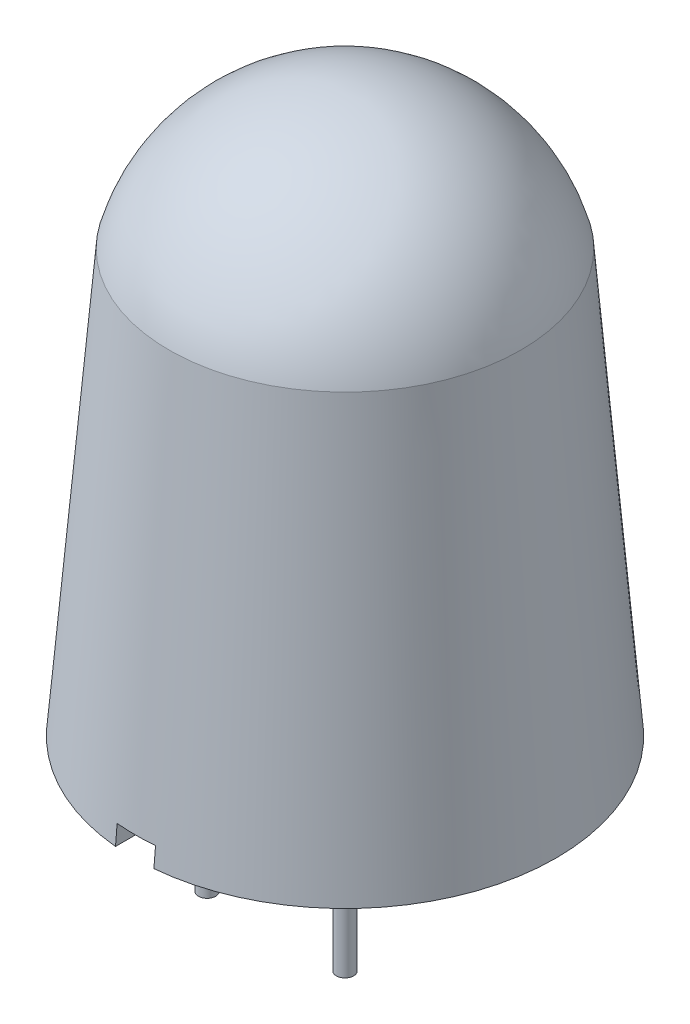
from build123d import *

# Parameters (mm, degrees)
SKETCH2_R               = 5
CUT_EXTRUDE1_DEPTH      = 1
CUT_EXTRUDE2_DEPTH      = 12
CUT_EXTRUDE2_DEPTH_BACK = 17.454482672
SKETCH3_W               = 1
SKETCH3_H               = 1
SKETCH4_R               = 0.225
BOSS_EXTRUDE1_DEPTH     = 4.5


with BuildPart() as part:
    # Sketch1 → Revolve1 (revolve)
    with BuildSketch(Plane.XY):
        with BuildLine():
            Line((0, 0), (5.5, 0))
            Line((5.5, 0), (4.582575695, 11))
            ThreePointArc((4.582575695, 11), (2.883140649, 13.524917218), (0, 14.5))
            Line((0, 14.5), (0, 0))
        make_face()
    revolve(axis=Axis((0, 0, 0), (0, 1, 0)))

    # Sketch2 → Cut-Extrude1 (cut)
    with BuildSketch(Plane.XZ):
        Circle(SKETCH2_R)
    extrude(amount=-CUT_EXTRUDE1_DEPTH, mode=Mode.SUBTRACT)

    # Sketch3 → Cut-Extrude2 (cut, two sides: drawn at the far end of the back side and taken through both)
    with BuildSketch(Plane.XY.offset(-CUT_EXTRUDE2_DEPTH_BACK)):
        Rectangle(SKETCH3_W, SKETCH3_H)
    extrude(amount=CUT_EXTRUDE2_DEPTH + CUT_EXTRUDE2_DEPTH_BACK, mode=Mode.SUBTRACT)

    # Sketch4 → Boss-Extrude1 (add)
    with BuildSketch(Plane.XZ.offset(-1)):
        with Locations((1.796051224, 1.796051224)):
            Circle(SKETCH4_R)
        with Locations((-1.796051224, 1.796051224)):
            Circle(SKETCH4_R)
        with Locations((-1.796051224, -1.796051224)):
            Circle(SKETCH4_R)
    extrude(amount=BOSS_EXTRUDE1_DEPTH)


solid = part.part
